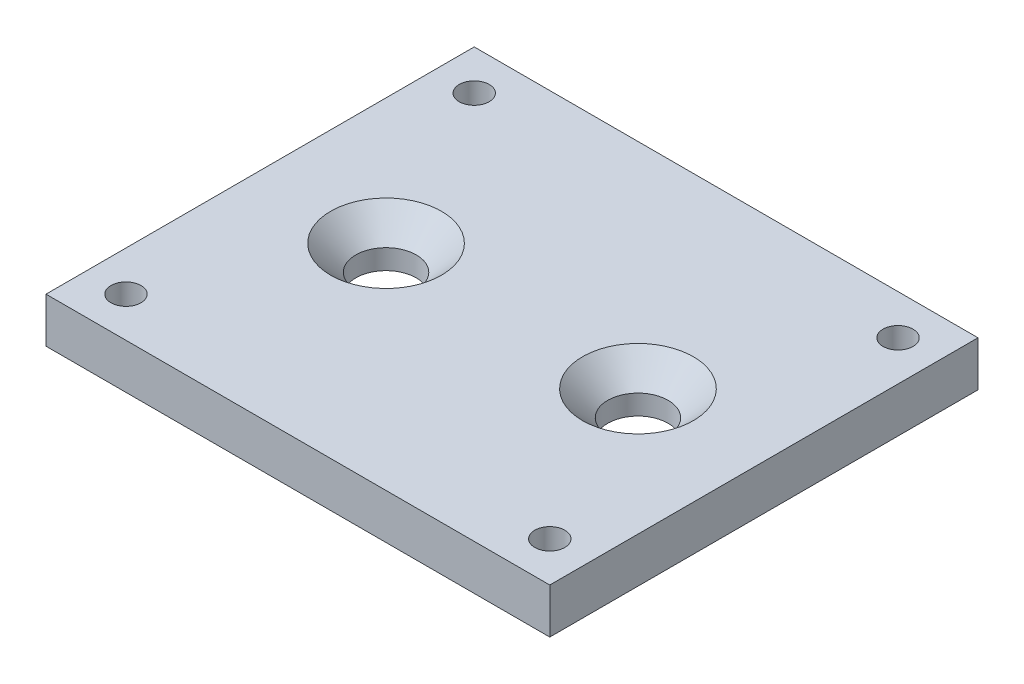
from build123d import *

# Parameters (mm, degrees)
SKETCH1_W                                      = 20
SKETCH1_H                                      = 17
BOSS_EXTRUDE1_DEPTH                            = 1.7907
F_0_80_TAPPED_HOLE1_D                          = 1.19126
CSK_FOR_M2_FLAT_HEAD_MACHINE_SCREW1_AT_2_COUNT = 2
CSK_FOR_M2_FLAT_HEAD_MACHINE_SCREW1_AT_2_PITCH = 10


with BuildPart() as part:
    # Sketch1 → Boss-Extrude1 (new body)
    with BuildSketch(Plane(origin=(0, 0, 0), x_dir=(1, 0, 0), z_dir=(0, 1, 0))):
        Rectangle(SKETCH1_W, SKETCH1_H)
    extrude(amount=BOSS_EXTRUDE1_DEPTH)

    # #0-80 Tapped Hole1 (through all)
    with Locations(Plane(origin=(0, 1.7907, 0), x_dir=(-1, 0, 0), z_dir=(0, 1, 0))):
        with Locations((-8.4125, -6.9125), (-8.4125, 6.9125), (8.4125, -6.9125), (8.4125, 6.9125)):
            Hole(F_0_80_TAPPED_HOLE1_D / 2)

    # Sketch4 → CSK for M2 Flat Head Machine Screw1 (revolve, cut)
    with BuildSketch(Plane(origin=(-5, 1.7907, 0), x_dir=(0, 0, 1), z_dir=(1, 0, 0))):
        Polygon((0, 0), (0, 1.7907), (1.2, 1.7907), (1.2, 1), (2.2, 0), align=None)
    csk_for_m2_flat_head_machine_screw1 = revolve(axis=Axis((-5, 8.1407, 0), (0, -1, 0)), mode=Mode.SUBTRACT)

    # CSK for M2 Flat Head Machine Screw1 at 2: CSK for M2 Flat Head Machine Screw1 ×2
    with Locations(*[(i * CSK_FOR_M2_FLAT_HEAD_MACHINE_SCREW1_AT_2_PITCH, 0, 0) for i in range(1, CSK_FOR_M2_FLAT_HEAD_MACHINE_SCREW1_AT_2_COUNT)]):
        add(csk_for_m2_flat_head_machine_screw1, mode=Mode.SUBTRACT)


solid = part.part
